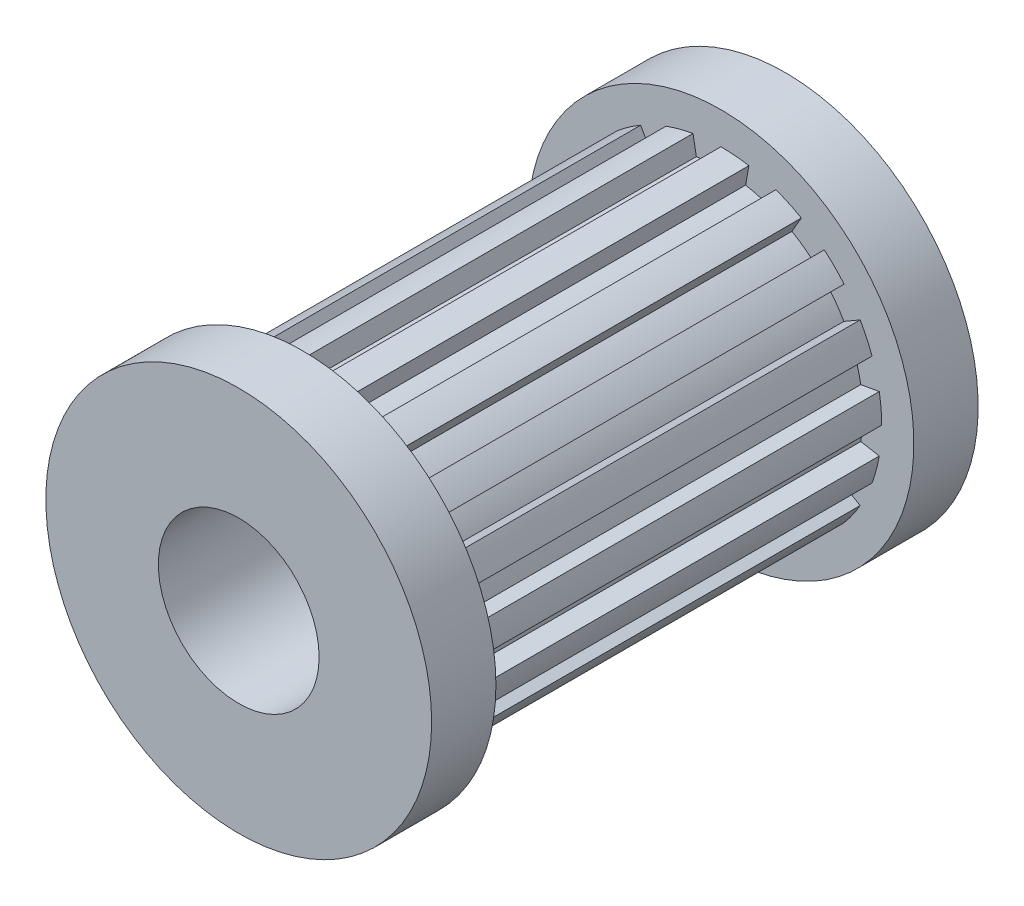
from build123d import *
from build123d.topology import SkipClean

# Parameters (mm, degrees)
SALIENTE_EXTRUIR1_DEPTH      = 7.5
SALIENTE_EXTRUIR1_DEPTH_BACK = 7.5
CROQUIS1_R                   = 2.5
SALIENTE_EXTRUIR2_START      = -2
CROQUIS2_R                   = 6
CROQUIS2_R_2                 = 2.5
SALIENTE_EXTRUIR2_DEPTH      = 2
SALIENTE_EXTRUIR3_START      = 2
CROQUIS3_R                   = 6
CROQUIS3_R_2                 = 2.5
SALIENTE_EXTRUIR3_DEPTH      = 2


with BuildPart() as part:
    # Croquis1 → Saliente-Extruir1 (new, two sides: drawn at the far end of the back side and taken through both)
    with BuildSketch(Plane.XY.offset(-SALIENTE_EXTRUIR1_DEPTH_BACK)):
        with BuildLine():
            Line((0, 4.41631546), (0, 5))
            ThreePointArc((0, 5), (0.435778714, 4.98097349), (0.868240888, 4.924038765))
            Line((0.868240888, 4.924038765), (0.766885132, 4.349221705))
            ThreePointArc((0.766885132, 4.349221705), (1.14302655, 4.26583316), (1.510468847, 4.149979049))
            Line((1.510468847, 4.149979049), (1.710100717, 4.698463104))
            ThreePointArc((1.710100717, 4.698463104), (2.113091309, 4.531538935), (2.5, 4.330127019))
            Line((2.5, 4.330127019), (2.20815773, 3.824641379))
            ThreePointArc((2.20815773, 3.824641379), (2.533094483, 3.617633837), (2.838752858, 3.383093917))
            Line((2.838752858, 3.383093917), (3.213938048, 3.830222216))
            ThreePointArc((3.213938048, 3.830222216), (3.535533906, 3.535533906), (3.830222216, 3.213938048))
            Line((3.830222216, 3.213938048), (3.383093917, 2.838752858))
            ThreePointArc((3.383093917, 2.838752858), (3.617633837, 2.533094483), (3.824641379, 2.20815773))
            Line((3.824641379, 2.20815773), (4.330127019, 2.5))
            ThreePointArc((4.330127019, 2.5), (4.531538935, 2.113091309), (4.698463104, 1.710100717))
            Line((4.698463104, 1.710100717), (4.149979049, 1.510468847))
            ThreePointArc((4.149979049, 1.510468847), (4.26583316, 1.14302655), (4.349221705, 0.766885132))
            Line((4.349221705, 0.766885132), (4.924038765, 0.868240888))
            ThreePointArc((4.924038765, 0.868240888), (4.98097349, 0.435778714), (5, 0))
            Line((5, 0), (4.41631546, 0))
            ThreePointArc((4.41631546, 0), (4.399510046, -0.384907254), (4.349221705, -0.766885132))
            Line((4.349221705, -0.766885132), (4.924038765, -0.868240888))
            ThreePointArc((4.924038765, -0.868240888), (4.829629131, -1.294095226), (4.698463104, -1.710100717))
            Line((4.698463104, -1.710100717), (4.149979049, -1.510468847))
            ThreePointArc((4.149979049, -1.510468847), (4.002541091, -1.866415563), (3.824641379, -2.20815773))
            Line((3.824641379, -2.20815773), (4.330127019, -2.5))
            ThreePointArc((4.330127019, -2.5), (4.095760221, -2.867882182), (3.830222216, -3.213938048))
            Line((3.830222216, -3.213938048), (3.383093917, -2.838752858))
            ThreePointArc((3.383093917, -2.838752858), (3.122806609, -3.122806609), (2.838752858, -3.383093917))
            Line((2.838752858, -3.383093917), (3.213938048, -3.830222216))
            ThreePointArc((3.213938048, -3.830222216), (2.867882182, -4.095760221), (2.5, -4.330127019))
            Line((2.5, -4.330127019), (2.20815773, -3.824641379))
            ThreePointArc((2.20815773, -3.824641379), (1.866415563, -4.002541091), (1.510468847, -4.149979049))
            Line((1.510468847, -4.149979049), (1.710100717, -4.698463104))
            ThreePointArc((1.710100717, -4.698463104), (1.294095226, -4.829629131), (0.868240888, -4.924038765))
            Line((0.868240888, -4.924038765), (0.766885132, -4.349221705))
            ThreePointArc((0.766885132, -4.349221705), (0.384907254, -4.399510046), (0, -4.41631546))
            Line((0, -4.41631546), (0, -5))
            ThreePointArc((0, -5), (-0.435778714, -4.98097349), (-0.868240888, -4.924038765))
            Line((-0.868240888, -4.924038765), (-0.766885132, -4.349221705))
            ThreePointArc((-0.766885132, -4.349221705), (-1.14302655, -4.26583316), (-1.510468847, -4.149979049))
            Line((-1.510468847, -4.149979049), (-1.710100717, -4.698463104))
            ThreePointArc((-1.710100717, -4.698463104), (-2.113091309, -4.531538935), (-2.5, -4.330127019))
            Line((-2.5, -4.330127019), (-2.20815773, -3.824641379))
            ThreePointArc((-2.20815773, -3.824641379), (-2.533094483, -3.617633837), (-2.838752858, -3.383093917))
            Line((-2.838752858, -3.383093917), (-3.213938048, -3.830222216))
            ThreePointArc((-3.213938048, -3.830222216), (-3.535533906, -3.535533906), (-3.830222216, -3.213938048))
            Line((-3.830222216, -3.213938048), (-3.383093917, -2.838752858))
            ThreePointArc((-3.383093917, -2.838752858), (-3.617633837, -2.533094483), (-3.824641379, -2.20815773))
            Line((-3.824641379, -2.20815773), (-4.330127019, -2.5))
            ThreePointArc((-4.330127019, -2.5), (-4.531538935, -2.113091309), (-4.698463104, -1.710100717))
            Line((-4.698463104, -1.710100717), (-4.149979049, -1.510468847))
            ThreePointArc((-4.149979049, -1.510468847), (-4.26583316, -1.14302655), (-4.349221705, -0.766885132))
            Line((-4.349221705, -0.766885132), (-4.924038765, -0.868240888))
            ThreePointArc((-4.924038765, -0.868240888), (-4.98097349, -0.435778714), (-5, 0))
            Line((-5, 0), (-4.41631546, 0))
            ThreePointArc((-4.41631546, 0), (-4.399510046, 0.384907254), (-4.349221705, 0.766885132))
            Line((-4.349221705, 0.766885132), (-4.924038765, 0.868240888))
            ThreePointArc((-4.924038765, 0.868240888), (-4.829629131, 1.294095226), (-4.698463104, 1.710100717))
            Line((-4.698463104, 1.710100717), (-4.149979049, 1.510468847))
            ThreePointArc((-4.149979049, 1.510468847), (-4.002541091, 1.866415563), (-3.824641379, 2.20815773))
            Line((-3.824641379, 2.20815773), (-4.330127019, 2.5))
            ThreePointArc((-4.330127019, 2.5), (-4.095760221, 2.867882182), (-3.830222216, 3.213938048))
            Line((-3.830222216, 3.213938048), (-3.383093917, 2.838752858))
            ThreePointArc((-3.383093917, 2.838752858), (-3.122806609, 3.122806609), (-2.838752858, 3.383093917))
            Line((-2.838752858, 3.383093917), (-3.213938048, 3.830222216))
            ThreePointArc((-3.213938048, 3.830222216), (-2.867882182, 4.095760221), (-2.5, 4.330127019))
            Line((-2.5, 4.330127019), (-2.20815773, 3.824641379))
            ThreePointArc((-2.20815773, 3.824641379), (-1.866415563, 4.002541091), (-1.510468847, 4.149979049))
            Line((-1.510468847, 4.149979049), (-1.710100717, 4.698463104))
            ThreePointArc((-1.710100717, 4.698463104), (-1.294095226, 4.829629131), (-0.868240888, 4.924038765))
            Line((-0.868240888, 4.924038765), (-0.766885132, 4.349221705))
            ThreePointArc((-0.766885132, 4.349221705), (-0.384907254, 4.399510046), (0, 4.41631546))
        make_face()
        Circle(CROQUIS1_R, mode=Mode.SUBTRACT)
    extrude(amount=SALIENTE_EXTRUIR1_DEPTH + SALIENTE_EXTRUIR1_DEPTH_BACK)

    # Croquis2 → Saliente-Extruir2 (add)
    with BuildSketch(Plane.XY.offset(7.5).offset(SALIENTE_EXTRUIR2_START)):
        Circle(CROQUIS2_R)
        Circle(CROQUIS2_R_2, mode=Mode.SUBTRACT)
    extrude(amount=SALIENTE_EXTRUIR2_DEPTH)

    # Croquis3 → Saliente-Extruir3 (add)
    with SkipClean():  # the faces are left unmerged after this step: merging them gives an invalid solid
        with BuildSketch(Plane(origin=(0, 0, -7.5), x_dir=(-1, 0, 0), z_dir=(0, 0, -1)).offset(SALIENTE_EXTRUIR3_START)):
            Circle(CROQUIS3_R)
            Circle(CROQUIS3_R_2, mode=Mode.SUBTRACT)
        extrude(amount=-SALIENTE_EXTRUIR3_DEPTH)


solid = part.part
